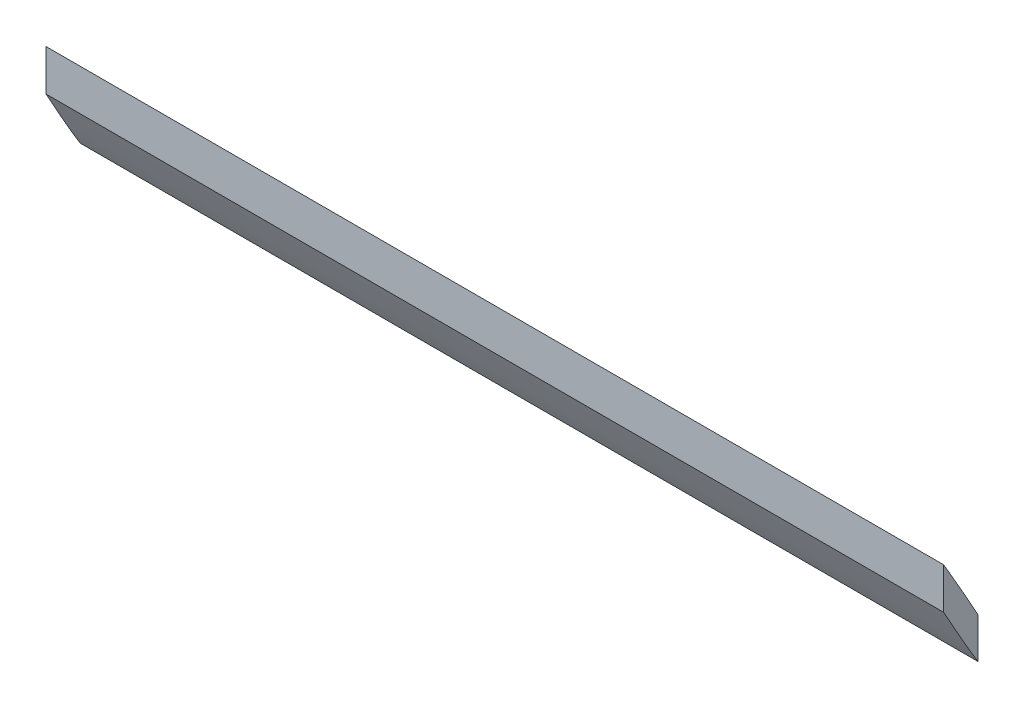
from build123d import *

# Parameters (mm, degrees)
BOSS_EXTRUDE1_DEPTH = 55


with BuildPart() as part:
    # Sketch1 → Boss-Extrude1 (new body)
    with BuildSketch(Plane(origin=(0, 0, 0), x_dir=(0, 0, -1), z_dir=(1, 0, 0))):
        with BuildLine():
            Line((-93.862132178, -48.29265664), (-93.862132178, -50.815195386))
            add(Edge.make_bspline(
                [(-93.862132178, -50.815195386), (-93.428724323, -51.590109603), (-93.001491452, -52.368743199), (-92.300291813, -53.587599451), (-92.036427489, -54.033907114), (-91.762132178, -54.47393188)],
                knots=[0.10625854, 0.10625854, 0.10625854, 0.10625854, 0.25, 0.25, 0.333977661, 0.333977661, 0.333977661, 0.333977661], degree=3))
            Line((-91.762132178, -54.47393188), (-91.762132178, -51.991456166))
            add(Edge.make_bspline(
                [(-91.762132178, -51.991456166), (-91.968330298, -51.626390185), (-92.172186308, -51.259756718), (-92.861800579, -50.020735858), (-93.347486201, -49.148183332), (-93.862132178, -48.29265664)],
                knots=[0.684770993, 0.684770993, 0.684770993, 0.684770993, 0.75, 0.75, 0.905319484, 0.905319484, 0.905319484, 0.905319484], degree=3))
        make_face()
    extrude(amount=BOSS_EXTRUDE1_DEPTH)


solid = part.part
